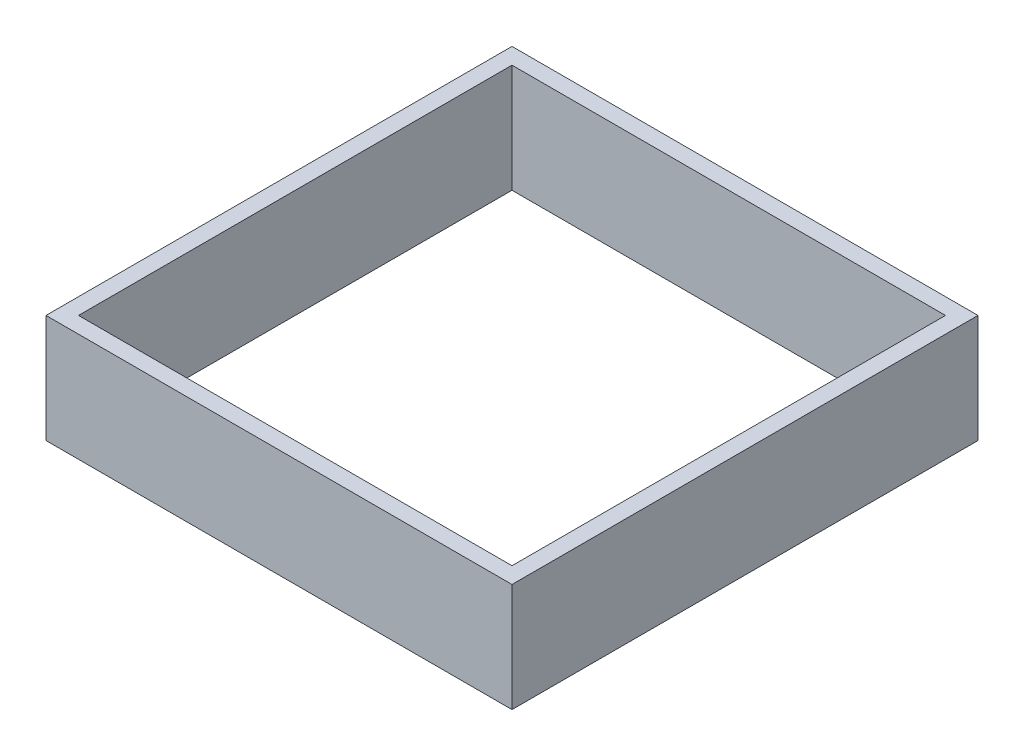
from build123d import *

# Parameters (mm, degrees)
SKETCH1_W           = 43
SKETCH1_H           = 43
SKETCH1_W_2         = 40
SKETCH1_H_2         = 40
BOSS_EXTRUDE1_DEPTH = 10


with BuildPart() as part:
    # Sketch1 → Boss-Extrude1 (new body)
    with BuildSketch(Plane(origin=(0, 0, 0), x_dir=(1, 0, 0), z_dir=(0, 1, 0))):
        Rectangle(SKETCH1_W, SKETCH1_H)
        Rectangle(SKETCH1_W_2, SKETCH1_H_2, mode=Mode.SUBTRACT)
    extrude(amount=BOSS_EXTRUDE1_DEPTH)


solid = part.part
